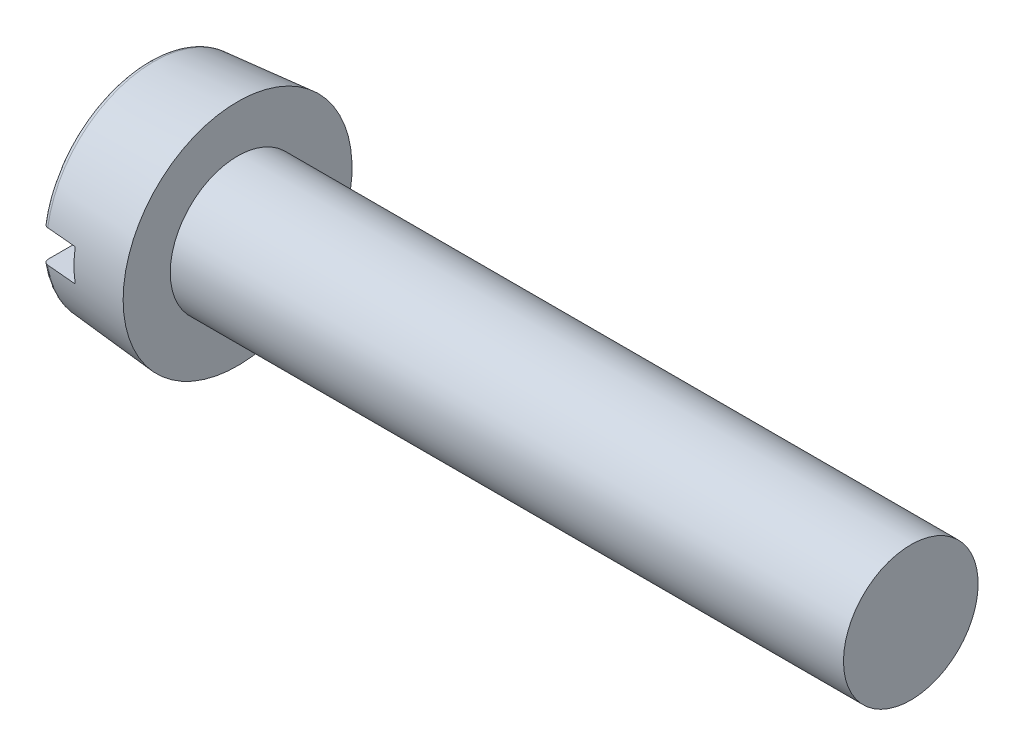
from build123d import *

# Parameters (mm, degrees)
FILLET2_R  = 0.2
SKETCH2_W  = 8.5
SKETCH2_H  = 1.2
SLOT_DEPTH = 1.3


with BuildPart() as part:
    # BodySke → Base-Revolve (revolve)
    with BuildSketch(Plane.XY):
        Polygon((3.3, 2.5), (3.3, 4.25), (0, 3.96128741), (0, 0), (28.3, 0), (28.3, 2.5), align=None)
    revolve(axis=Axis((-25.4, 0, 0), (1, 0, 0)))

    # Fillet2
    fillet2_edges = [part.edges().sort_by_distance(p)[0] for p in [
        (0, -3.96128741, 0),
    ]]
    fillet(fillet2_edges, radius=FILLET2_R)

    # Sketch2 → Slot (cut)
    with BuildSketch(Plane(origin=(0, 0, 0), x_dir=(0, 0, -1), z_dir=(1, 0, 0))):
        Rectangle(SKETCH2_W, SKETCH2_H)
    extrude(amount=SLOT_DEPTH, mode=Mode.SUBTRACT)


solid = part.part
